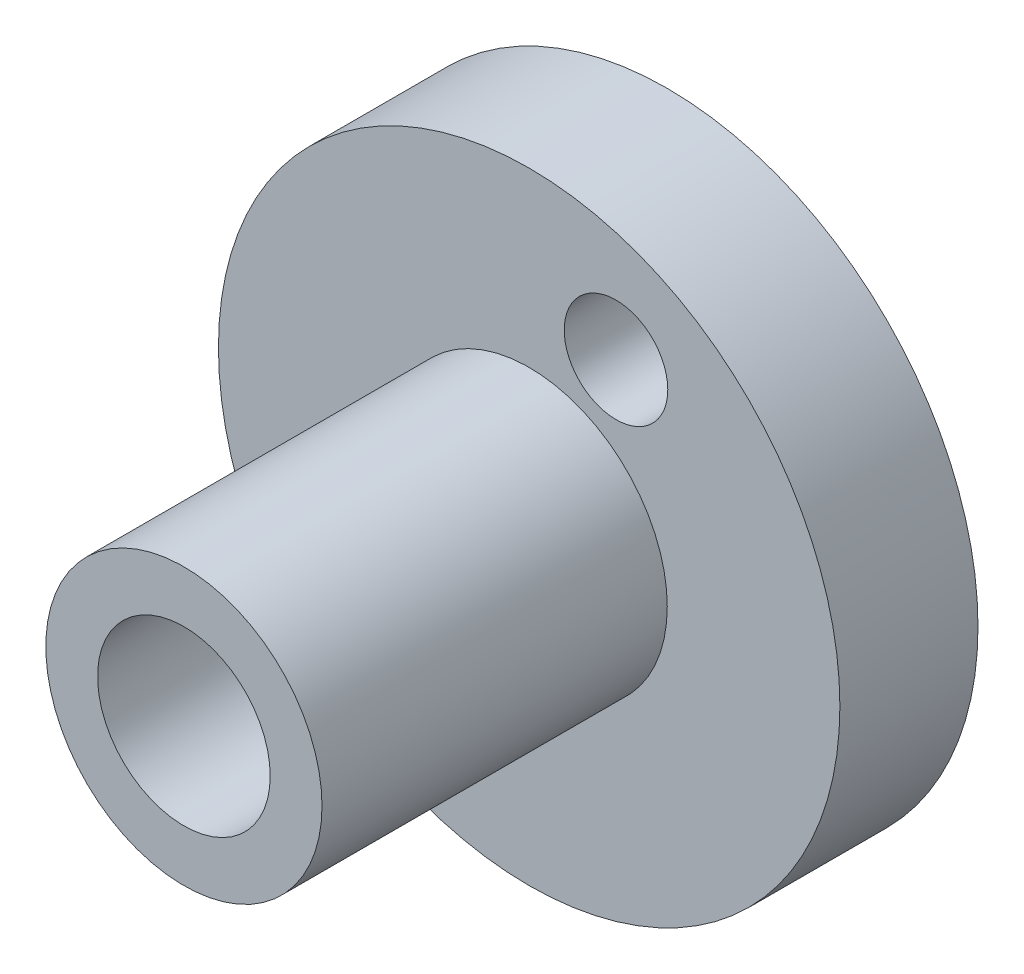
from build123d import *

# Parameters (mm, degrees)
SKETCH_1_R               = 18
SKETCH_1_R_2             = 5
EXTRUDE_1_DEPTH          = 8
SKETCH_2_R               = 8
SKETCH_2_R_2             = 5
EXTRUDE_2_DEPTH          = 20
SKETCH_3_R               = 3
CUT_EXTRUDE_1_DEPTH      = 20
PATTERN_CIRCULAR_1_COUNT = 2


with BuildPart() as part:
    # Эскиз1 → Бобышка-Вытянуть1 (new body)
    with BuildSketch(Plane.XY):
        Circle(SKETCH_1_R)
        Circle(SKETCH_1_R_2, mode=Mode.SUBTRACT)
    extrude(amount=EXTRUDE_1_DEPTH)

    # Эскиз2 → Бобышка-Вытянуть2 (add)
    with BuildSketch(Plane.XY.offset(8)):
        Circle(SKETCH_2_R)
        Circle(SKETCH_2_R_2, mode=Mode.SUBTRACT)
    extrude(amount=EXTRUDE_2_DEPTH)

    # Эскиз3 → Вырез-Вытянуть1 (cut)
    with BuildSketch(Plane(origin=(0, 0, 0), x_dir=(-1, 0, 0), z_dir=(0, 0, -1))):
        with Locations((5.029540605, -10.89512374)):
            Circle(SKETCH_3_R)
    cut_extrude_1 = extrude(amount=-CUT_EXTRUDE_1_DEPTH, mode=Mode.SUBTRACT)

    # Круговой массив1: Вырез-Вытянуть1 ×2 about axis
    pattern_circular_1_axis = Axis((0, 0, 0), (0, 0, 1))
    for i in range(1, PATTERN_CIRCULAR_1_COUNT):
        add(cut_extrude_1.rotate(pattern_circular_1_axis, i * 360 / PATTERN_CIRCULAR_1_COUNT), mode=Mode.SUBTRACT)


solid = part.part
